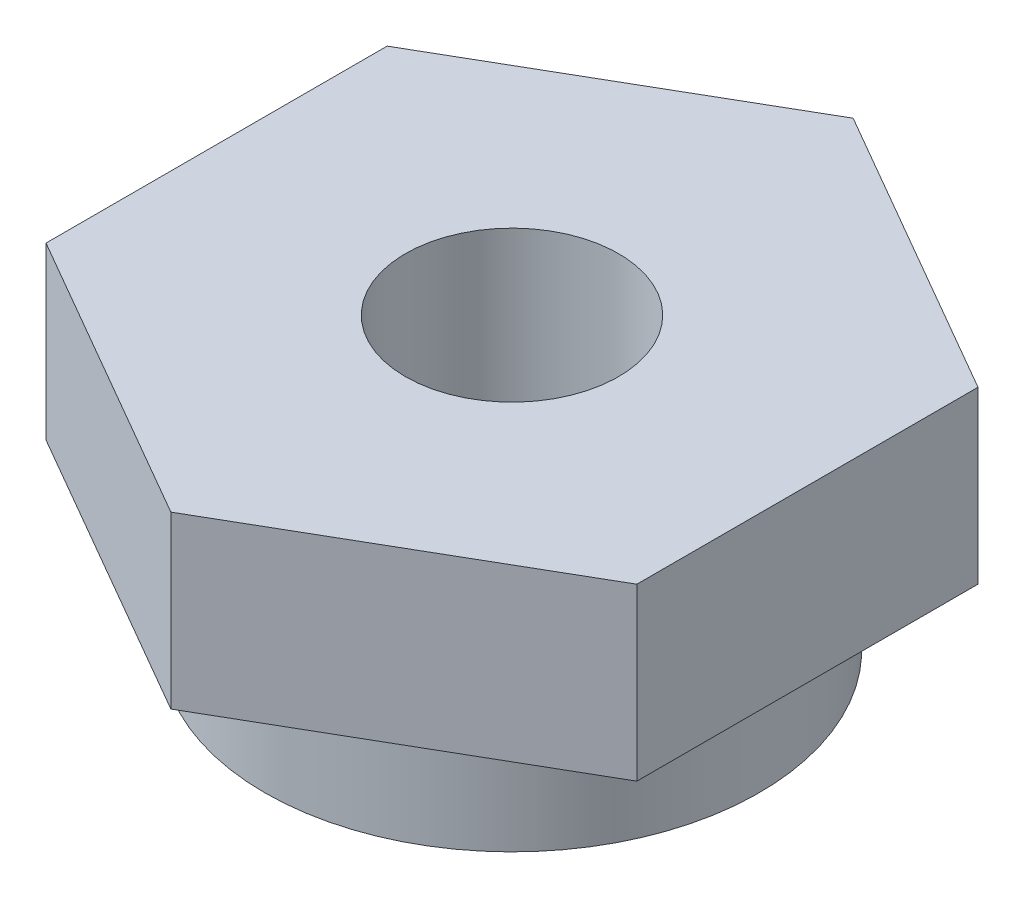
from build123d import *

# Parameters (mm, degrees)
SKETCH1_R           = 9.2075
SKETCH1_R_2         = 3.96875
BOSS_EXTRUDE1_DEPTH = 4.445
SKETCH2_R           = 3.96875
BOSS_EXTRUDE2_DEPTH = 6.35


with BuildPart() as part:
    # Sketch1 → Boss-Extrude1 (new body)
    with BuildSketch(Plane(origin=(0, 0, 0), x_dir=(1, 0, 0), z_dir=(0, 1, 0))):
        with Locations(Location((0, 0, 0), (0, 0, 270))):  # turned: the seam where the file's is
            Circle(SKETCH1_R)
        with Locations(Location((0, 0, 0), (0, 0, 270))):  # turned: the seam where the file's is
            Circle(SKETCH1_R_2, mode=Mode.SUBTRACT)
    extrude(amount=BOSS_EXTRUDE1_DEPTH)

    # Sketch2 → Boss-Extrude2 (add)
    with BuildSketch(Plane(origin=(0, 4.445, 0), x_dir=(1, 0, 0), z_dir=(0, 1, 0))):
        Polygon((0, 12.7), (-10.998522628, 6.35), (-10.998522628, -6.35), (0, -12.7), (10.998522628, -6.35), (10.998522628, 6.35), align=None)
        with Locations(Location((0, 0, 0), (0, 0, 270))):  # turned: the seam where the file's is
            Circle(SKETCH2_R, mode=Mode.SUBTRACT)
    extrude(amount=BOSS_EXTRUDE2_DEPTH)


solid = part.part
